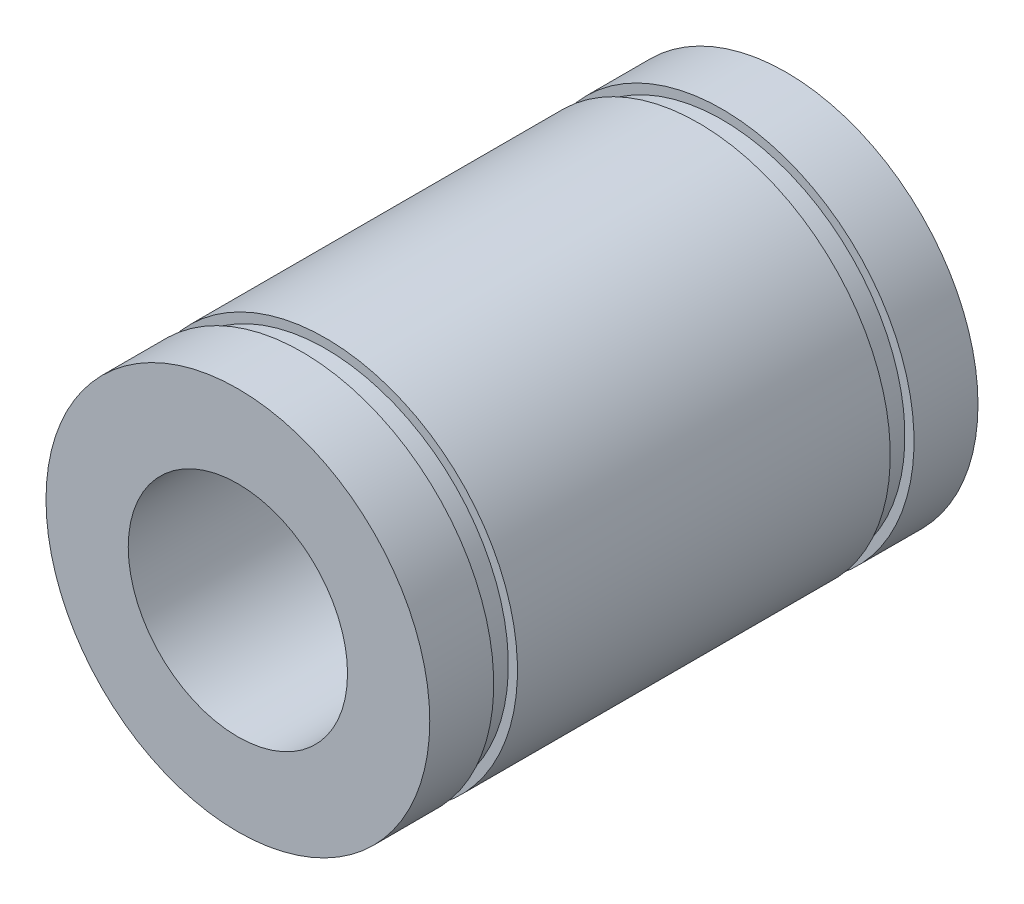
from build123d import *

# Parameters (mm, degrees)
ESBO_O1_R                  = 10.5
RESSALTO_EXTRUS_O1_DEPTH   = 30
ESBO_O2_R                  = 6
CORTE_EXTRUS_O1_DEPTH      = 1
CORTE_EXTRUS_O1_DEPTH_BACK = 31
ESBO_O4_W                  = 1.3
ESBO_O4_H                  = 0.5


with BuildPart() as part:
    # Esboço1 → Ressalto-extrusão1 (new body)
    with BuildSketch(Plane.XY):
        Circle(ESBO_O1_R)
    extrude(amount=RESSALTO_EXTRUS_O1_DEPTH)

    # Esboço2 → Corte-extrusão1 (cut, two sides)
    with BuildSketch(Plane.XY.offset(30)) as corte_extrus_o1_sk:
        Circle(ESBO_O2_R)
    extrude(amount=CORTE_EXTRUS_O1_DEPTH, mode=Mode.SUBTRACT)
    extrude(corte_extrus_o1_sk.sketch, amount=-CORTE_EXTRUS_O1_DEPTH_BACK, mode=Mode.SUBTRACT)

    # Esboço4 → Corte-Revolução1 (revolve, cut)
    with BuildSketch(Plane(origin=(0, 0, 0), x_dir=(0, 0, -1), z_dir=(1, 0, 0))):
        with Locations((-25.85, 10.25)):
            Rectangle(ESBO_O4_W, ESBO_O4_H)
        with Locations((-4.15, 10.25)):
            Rectangle(ESBO_O4_W, ESBO_O4_H)
    revolve(axis=Axis((0, 0, -1.457000242), (0, 0, 1)), mode=Mode.SUBTRACT)


solid = part.part
